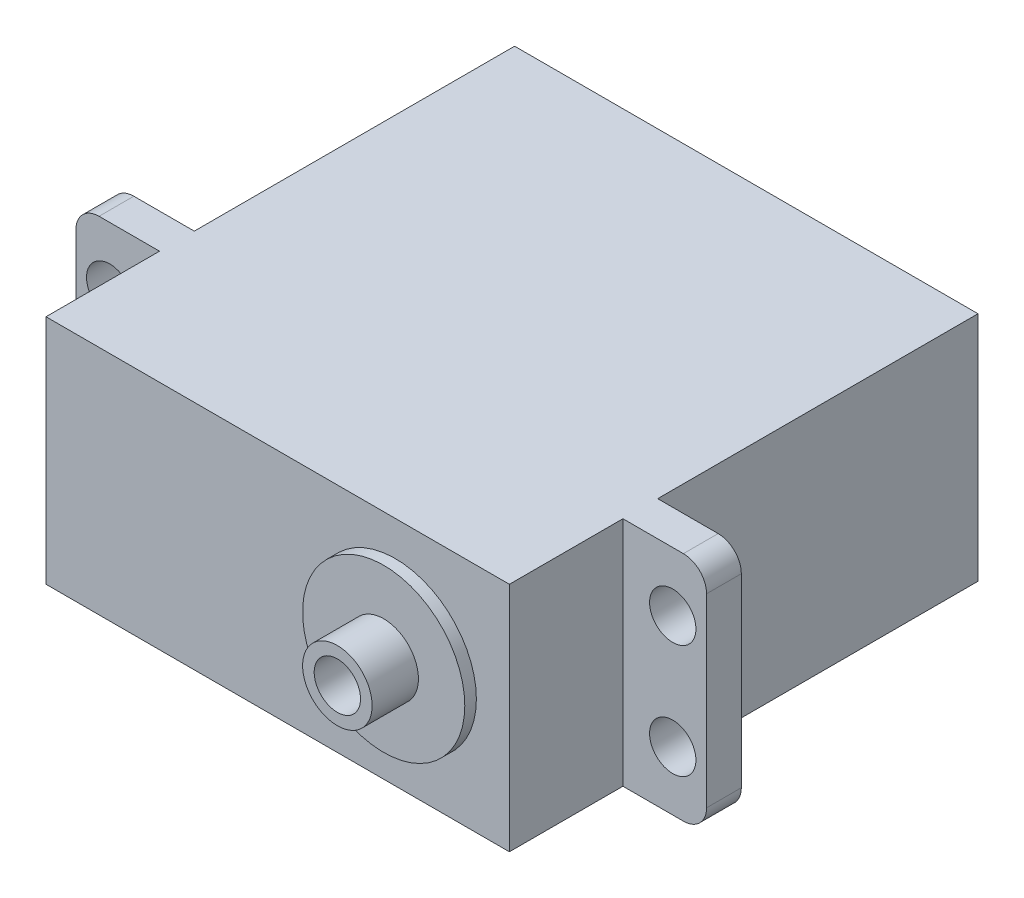
from build123d import *

# Parameters (mm, degrees)
SKETCH2_W           = 40
SKETCH2_H           = 20
BOSS_EXTRUDE1_DEPTH = 27.65
SKETCH3_W           = 54.44
SKETCH3_H           = 20
SKETCH3_R           = 2
BOSS_EXTRUDE2_DEPTH = 3
SKETCH4_W           = 40
SKETCH4_H           = 20
BOSS_EXTRUDE3_DEPTH = 9.8
SKETCH5_R           = 7
BOSS_EXTRUDE4_DEPTH = 1
SKETCH6_R           = 3
BOSS_EXTRUDE5_DEPTH = 4
FILLET1_R           = 2
SKETCH7_R           = 2
CUT_EXTRUDE1_DEPTH  = 10


with BuildPart() as part:
    # Sketch2 → Boss-Extrude1 (new body)
    with BuildSketch(Plane.XY):
        with Locations((-33.592215537, 218.387921433)):
            Rectangle(SKETCH2_W, SKETCH2_H)
    extrude(amount=BOSS_EXTRUDE1_DEPTH)

    # Sketch3 → Boss-Extrude2 (add)
    with BuildSketch(Plane.XY.offset(27.65)):
        with Locations((-33.592215537, 218.387921433)):
            Rectangle(SKETCH3_W, SKETCH3_H)
        with Locations((-9.292215537, 213.487921433)):
            Circle(SKETCH3_R, mode=Mode.SUBTRACT)
        with Locations((-9.292215537, 223.287921433)):
            Circle(SKETCH3_R, mode=Mode.SUBTRACT)
        with Locations((-57.892215537, 223.287921433)):
            Circle(SKETCH3_R, mode=Mode.SUBTRACT)
        with Locations((-57.892215537, 213.487921433)):
            Circle(SKETCH3_R, mode=Mode.SUBTRACT)
    extrude(amount=BOSS_EXTRUDE2_DEPTH)

    # Sketch4 → Boss-Extrude3 (add)
    with BuildSketch(Plane.XY.offset(30.65)):
        with Locations((-33.592215537, 218.387921433)):
            Rectangle(SKETCH4_W, SKETCH4_H)
    extrude(amount=BOSS_EXTRUDE3_DEPTH)

    # Sketch5 → Boss-Extrude4 (add)
    with BuildSketch(Plane.XY.offset(40.45)):
        with Locations((-23.442215537, 218.387921433)):
            Circle(SKETCH5_R)
    extrude(amount=BOSS_EXTRUDE4_DEPTH)

    # Sketch6 → Boss-Extrude5 (add)
    with BuildSketch(Plane.XY.offset(41.45)):
        with Locations((-23.442215537, 218.387921433)):
            Circle(SKETCH6_R)
    extrude(amount=BOSS_EXTRUDE5_DEPTH)

    # Fillet1
    fillet1_edges = [part.edges().sort_by_distance(p)[0] for p in [
        (-6.372215537, 208.387921433, 29.15),
        (-60.812215537, 208.387921433, 29.15),
        (-6.372215537, 228.387921433, 29.15),
        (-60.812215537, 228.387921433, 29.15),
    ]]
    fillet(fillet1_edges, radius=FILLET1_R)

    # Sketch7 → Cut-Extrude1 (cut)
    with BuildSketch(Plane.XY.offset(45.45)):
        with Locations((-23.442215537, 218.387921433)):
            Circle(SKETCH7_R)
    extrude(amount=-CUT_EXTRUDE1_DEPTH, mode=Mode.SUBTRACT)


solid = part.part
